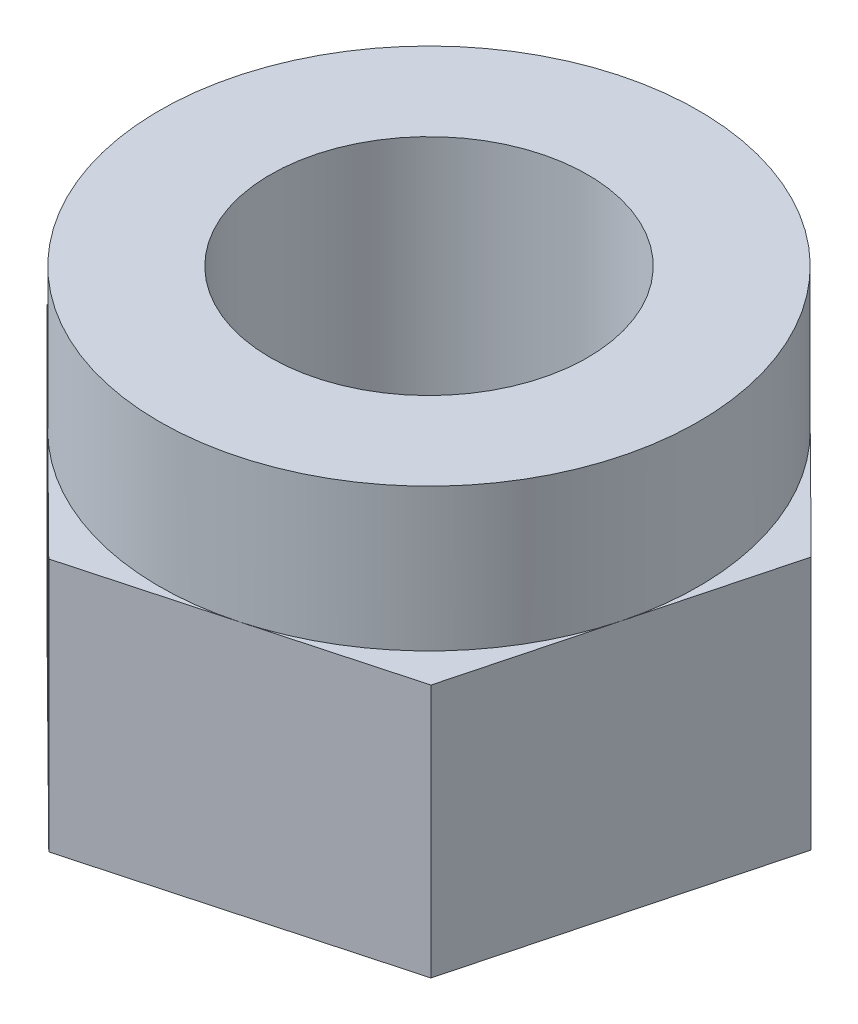
from build123d import *

# Parameters (mm, degrees)
EXTRUDE_1_DEPTH     = 3.2
EXTRUDE_2_DEPTH     = 5
SKETCH_2_R          = 2
CUT_EXTRUDE_1_DEPTH = 5


with BuildPart() as part:
    # 草图1 → 凸台-拉伸1 (new body)
    with BuildSketch(Plane(origin=(0, 0, 0), x_dir=(1, 0, 0), z_dir=(0, 1, 0))):
        Polygon((3.787584707, 1.033216056), (0.999001002, 3.796752603), (-2.788583706, 2.763536548), (-3.787584707, -1.033216056), (-0.999001002, -3.796752603), (2.788583706, -2.763536548), align=None)
    extrude(amount=EXTRUDE_1_DEPTH)

    # 草图1<3> → 凸台-拉伸2 (add)
    with BuildSketch(Plane(origin=(0, 0, 0), x_dir=(1, 0, 0), z_dir=(0, 1, 0))):
        with BuildLine():
            ThreePointArc((3.4, 0), (3.13824753, 1.308205811), (2.39329268, 2.414984502))
            ThreePointArc((2.39329268, 2.414984502), (0.865160253, 3.288084205), (-0.894791101, 3.280144644))
            ThreePointArc((-0.894791101, 3.280144644), (-2.414984144, 2.393293042), (-3.288084139, 0.865160504))
            ThreePointArc((-3.288084139, 0.865160504), (-3.280144574, -0.894791357), (-2.393292658, -2.414984524))
            ThreePointArc((-2.393292658, -2.414984524), (-0.865160223, -3.288084212), (0.894791131, -3.280144636))
            ThreePointArc((0.894791131, -3.280144636), (2.414984165, -2.39329302), (3.288084146, -0.865160476))
            ThreePointArc((3.288084146, -0.865160476), (3.371904958, -0.436184539), (3.4, 0))
        make_face()
    extrude(amount=EXTRUDE_2_DEPTH)

    # 草图2 → 切除-拉伸1 (cut)
    with BuildSketch(Plane(origin=(0, 0, 0), x_dir=(1, 0, 0), z_dir=(0, 1, 0))):
        Circle(SKETCH_2_R)
    extrude(amount=CUT_EXTRUDE_1_DEPTH, mode=Mode.SUBTRACT)


solid = part.part
